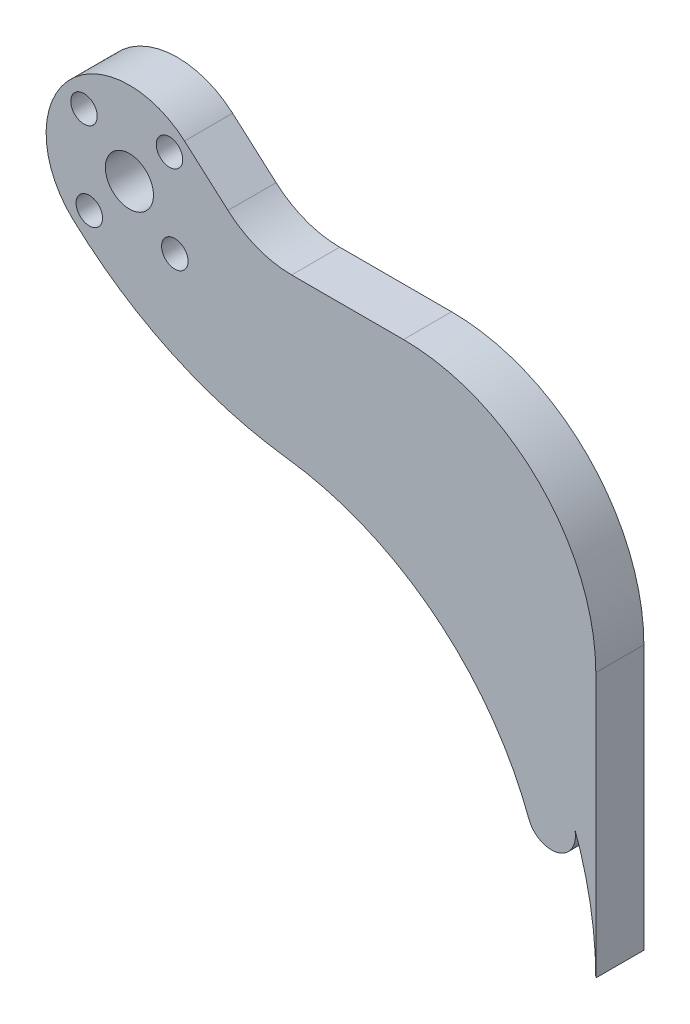
from build123d import *

# Parameters (mm, degrees)
BOSS_EXTRUDE1_DEPTH = 6.35
SKETCH2_R           = 3.175
SKETCH2_R_2         = 1.75
CUT_EXTRUDE1_DEPTH  = 7.35
BOSS_EXTRUDE2_DEPTH = 6.35
FILLET1_R           = 12.7
FILLET2_R           = 25.4


with BuildPart() as part:
    # Sketch1 → Boss-Extrude1 (new body)
    with BuildSketch(Plane.XY):
        with BuildLine():
            Line((-8.595455009, 68.571709933), (30.25643609, 34.276325287))
            ThreePointArc((30.25643609, 34.276325287), (37.667757847, 25.912514713), (42.82871051, 16.000623615))
            ThreePointArc((42.82871051, 16.000623615), (40.96564892, 11.91525319), (36.880278494, 13.77831478))
            ThreePointArc((36.880278494, 13.77831478), (24.419435892, 30.881840145), (4.903675305, 39.063421106))
            ThreePointArc((4.903675305, 39.063421106), (-10.270602503, 43.44261231), (-23.366607565, 52.270447493))
            ThreePointArc((-23.366607565, 52.270447493), (-24.02632087, 67.711201194), (-8.595455009, 68.571709933))
        make_face()
    extrude(amount=BOSS_EXTRUDE1_DEPTH)

    # Sketch2 → Cut-Extrude1 (cut, through all)
    with BuildSketch(Plane.XY.offset(6.35)):
        with Locations((-15.875, 60.325)):
            Circle(SKETCH2_R)
        with Locations((-10.580785461, 66.322607224)):
            Circle(SKETCH2_R_2)
        with Locations((-9.877392776, 55.030785461)):
            Circle(SKETCH2_R_2)
        with Locations((-21.169214539, 54.327392776)):
            Circle(SKETCH2_R_2)
        with Locations((-21.872607224, 65.619214539)):
            Circle(SKETCH2_R_2)
    extrude(amount=-CUT_EXTRUDE1_DEPTH, mode=Mode.SUBTRACT)

    # Sketch3 → Boss-Extrude2 (add, through all)
    with BuildSketch(Plane(origin=(0, 0, 0), x_dir=(-1, 0, 0), z_dir=(0, 0, -1))):
        with BuildLine():
            Line((-0.746918011, 60.325), (-45.72, 60.325))
            Line((-45.72, 60.325), (-45.72, 0))
            ThreePointArc((-45.72, 0), (-41.67518841, 18.801517784), (-30.25643609, 34.276325287))
            Line((-30.25643609, 34.276325287), (-0.746918011, 60.325))
        make_face()
    extrude(amount=-BOSS_EXTRUDE2_DEPTH)

    # Fillet1
    fillet1_edges = [part.edges().sort_by_distance(p)[0] for p in [
        (0.746918011, 60.325, 3.175),
    ]]
    fillet(fillet1_edges, radius=FILLET1_R)

    # Fillet2
    fillet2_edges = [part.edges().sort_by_distance(p)[0] for p in [
        (45.72, 60.325, 3.175),
    ]]
    fillet(fillet2_edges, radius=FILLET2_R)


solid = part.part
